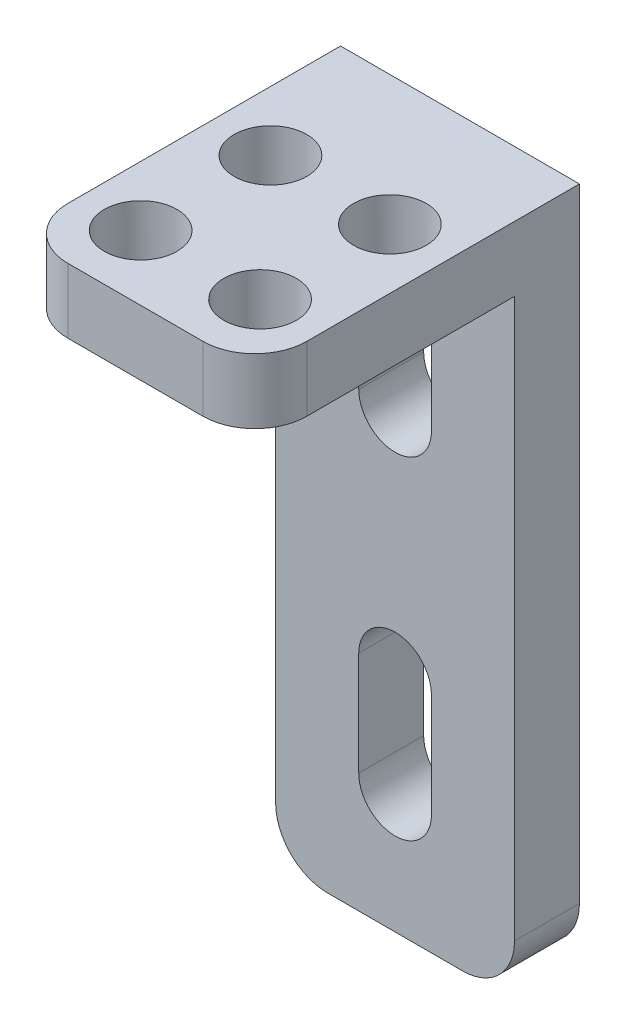
from build123d import *

# Parameters (mm, degrees)
SKETCH1_W           = 11.684
SKETCH1_H           = 33.02
BOSS_EXTRUDE1_DEPTH = 3.175
SKETCH2_W           = 11.684
SKETCH2_H           = 3.175
BOSS_EXTRUDE2_DEPTH = 12.7
CUT_EXTRUDE2_REACH  = 35.02
SKETCH3_R           = 1.778
FILLET2_R           = 2.54


with BuildPart() as part:
    # Sketch1 → Boss-Extrude1 (new body)
    with BuildSketch(Plane.XY):
        with Locations((0.021673222, 0)):
            Rectangle(SKETCH1_W, SKETCH1_H)
        with BuildLine():
            Line((-1.756326778, 5.588), (-1.756326778, 10.668))
            ThreePointArc((-1.756326778, 10.668), (0.021673222, 12.446), (1.799673222, 10.668))
            Line((1.799673222, 10.668), (1.799673222, 5.588))
            ThreePointArc((1.799673222, 5.588), (0.021673222, 3.81), (-1.756326778, 5.588))
        make_face(mode=Mode.SUBTRACT)
        with BuildLine():
            Line((-1.756326778, -5.588), (-1.756326778, -10.668))
            ThreePointArc((-1.756326778, -10.668), (0.021673222, -12.446), (1.799673222, -10.668))
            Line((1.799673222, -10.668), (1.799673222, -5.588))
            ThreePointArc((1.799673222, -5.588), (0.021673222, -3.81), (-1.756326778, -5.588))
        make_face(mode=Mode.SUBTRACT)
    extrude(amount=BOSS_EXTRUDE1_DEPTH)

    # Sketch2 → Boss-Extrude2 (add)
    with BuildSketch(Plane.XY.offset(3.175)):
        with Locations((0.021673222, 14.9225)):
            Rectangle(SKETCH2_W, SKETCH2_H)
    extrude(amount=BOSS_EXTRUDE2_DEPTH)

    # Sketch3 → Cut-Extrude2 (cut, up to next)
    with BuildSketch(Plane(origin=(0, 16.51, 0), x_dir=(1, 0, 0), z_dir=(0, 1, 0)), mode=Mode.PRIVATE) as cut_extrude2_sk1:
        with Locations((-2.899326778, -6.35)):
            Circle(SKETCH3_R)
    cut_extrude2_tool1 = extrude(cut_extrude2_sk1.sketch, amount=-CUT_EXTRUDE2_REACH, mode=Mode.PRIVATE) & part.part
    add(cut_extrude2_tool1.solids().sort_by_distance((-2.899327, 16.51, 6.35))[0], mode=Mode.SUBTRACT)
    # Sketch3 → Cut-Extrude2 (cut, up to next)
    with BuildSketch(Plane(origin=(0, 16.51, 0), x_dir=(1, 0, 0), z_dir=(0, 1, 0)), mode=Mode.PRIVATE) as cut_extrude2_sk2:
        with Locations((2.942673222, -6.35)):
            Circle(SKETCH3_R)
    cut_extrude2_tool2 = extrude(cut_extrude2_sk2.sketch, amount=-CUT_EXTRUDE2_REACH, mode=Mode.PRIVATE) & part.part
    add(cut_extrude2_tool2.solids().sort_by_distance((2.942673, 16.51, 6.35))[0], mode=Mode.SUBTRACT)
    # Sketch3 → Cut-Extrude2 (cut, up to next)
    with BuildSketch(Plane(origin=(0, 16.51, 0), x_dir=(1, 0, 0), z_dir=(0, 1, 0)), mode=Mode.PRIVATE) as cut_extrude2_sk3:
        with Locations((-2.899326778, -12.7)):
            Circle(SKETCH3_R)
    cut_extrude2_tool3 = extrude(cut_extrude2_sk3.sketch, amount=-CUT_EXTRUDE2_REACH, mode=Mode.PRIVATE) & part.part
    add(cut_extrude2_tool3.solids().sort_by_distance((-2.899327, 16.51, 12.7))[0], mode=Mode.SUBTRACT)
    # Sketch3 → Cut-Extrude2 (cut, up to next)
    with BuildSketch(Plane(origin=(0, 16.51, 0), x_dir=(1, 0, 0), z_dir=(0, 1, 0)), mode=Mode.PRIVATE) as cut_extrude2_sk4:
        with Locations((2.942673222, -12.7)):
            Circle(SKETCH3_R)
    cut_extrude2_tool4 = extrude(cut_extrude2_sk4.sketch, amount=-CUT_EXTRUDE2_REACH, mode=Mode.PRIVATE) & part.part
    add(cut_extrude2_tool4.solids().sort_by_distance((2.942673, 16.51, 12.7))[0], mode=Mode.SUBTRACT)

    # Fillet2
    fillet2_edges = [part.edges().sort_by_distance(p)[0] for p in [
        (-5.820326778, 14.9225, 15.875),
        (5.863673222, 14.9225, 15.875),
        (5.863673222, -16.51, 1.5875),
        (-5.820326778, -16.51, 1.5875),
    ]]
    fillet(fillet2_edges, radius=FILLET2_R)


solid = part.part
